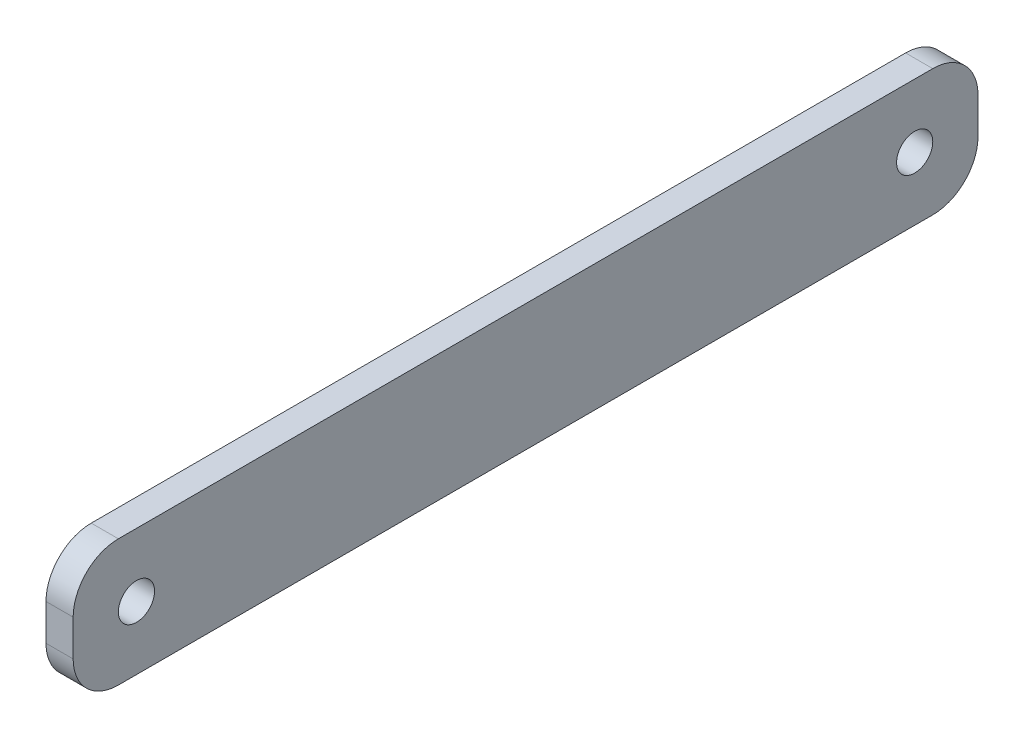
from build123d import *

# Parameters (mm, degrees)
SKETCH2_W           = 100
SKETCH2_H           = 14
SKETCH2_R           = 2
BOSS_EXTRUDE2_DEPTH = 3
FILLET1_R           = 5


with BuildPart() as part:
    # Sketch2 → Boss-Extrude2 (new body)
    with BuildSketch(Plane(origin=(0, 0, 0), x_dir=(0, 0, -1), z_dir=(1, 0, 0))):
        with Locations((50, 7)):
            Rectangle(SKETCH2_W, SKETCH2_H)
        with Locations((7, 7)):
            Circle(SKETCH2_R, mode=Mode.SUBTRACT)
        with Locations((93, 7)):
            Circle(SKETCH2_R, mode=Mode.SUBTRACT)
    extrude(amount=BOSS_EXTRUDE2_DEPTH)

    # Fillet1
    fillet1_edges = [part.edges().sort_by_distance(p)[0] for p in [
        (1.5, 14, 0),
        (1.5, 14, -100),
        (1.5, 0, -100),
        (1.5, 0, 0),
    ]]
    fillet(fillet1_edges, radius=FILLET1_R)


solid = part.part
